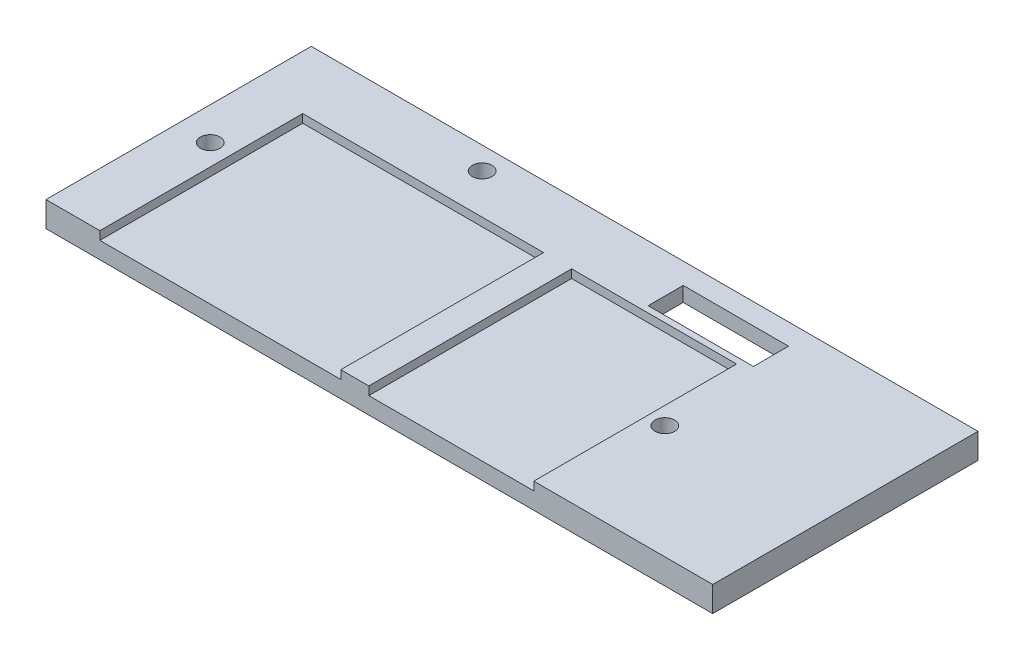
from build123d import *

# Parameters (mm, degrees)
SKETCH1_W           = 95
SKETCH1_H           = 37.8
BOSS_EXTRUDE1_DEPTH = 3.6
SKETCH2_R           = 1.4
CUT_EXTRUDE1_DEPTH  = 4
SKETCH3_W           = 6
SKETCH3_H           = 6
SKETCH3_W_2         = 7
SKETCH3_H_2         = 5
SKETCH3_W_3         = 5
CUT_EXTRUDE5_DEPTH  = 1.5
BOSS_EXTRUDE3_DEPTH = 1.5
SKETCH6_W           = 15
SKETCH6_H           = 5
CUT_EXTRUDE6_DEPTH  = 18.5
SKETCH7_W           = 10
SKETCH7_H           = 1.5
CUT_EXTRUDE7_DEPTH  = 2
SKETCH9_W           = 23
SKETCH9_H           = 1.5
CUT_EXTRUDE8_DEPTH  = 1.5
SKETCH10_W          = 18
SKETCH10_H          = 1.5
BOSS_EXTRUDE5_DEPTH = 1.5
SKETCH11_W          = 34.32
SKETCH11_H          = 28.9
SKETCH11_W_2        = 23.5
CUT_EXTRUDE10_DEPTH = 1.2
SKETCH12_W          = 1.5
SKETCH12_H          = 1.5
BOSS_EXTRUDE6_DEPTH = 0.5


with BuildPart() as part:
    # Sketch1 → Boss-Extrude1 (new body)
    with BuildSketch(Plane(origin=(0, 0, 0), x_dir=(1, 0, 0), z_dir=(0, 1, 0))):
        Rectangle(SKETCH1_W, SKETCH1_H)
    extrude(amount=BOSS_EXTRUDE1_DEPTH)

    # Sketch2 → Cut-Extrude1 (cut)
    with BuildSketch(Plane(origin=(0, 3.6, 0), x_dir=(1, 0, 0), z_dir=(0, 1, 0))):
        with Locations((-42.82, -0.18)):
            Circle(SKETCH2_R)
        with Locations((-19.96, 15.7)):
            Circle(SKETCH2_R)
        with Locations((24.5, -2.72)):
            Circle(SKETCH2_R)
    extrude(amount=-CUT_EXTRUDE1_DEPTH, mode=Mode.SUBTRACT)

    # Sketch3 → Cut-Extrude5 (cut)
    with BuildSketch(Plane.XZ):
        with Locations((-37.82, -9.62)):
            Rectangle(SKETCH3_W, SKETCH3_H)
        Polygon((28, -18.9), (7, -18.9), (7, -8.9), (11, -8.9), (28, -8.9), align=None)
        with BuildLine():
            Line((-19.26, -6.1), (-19.26, 15.9))
            Line((-19.26, 15.9), (22.74, 15.9))
            Line((22.74, 15.9), (22.74, 4.12))
            Line((22.74, 4.12), (24.5, 4.12))
            ThreePointArc((24.5, 4.12), (25.9, 2.72), (24.5, 1.32))
            Line((24.5, 1.32), (22.74, 1.32))
            Line((22.74, 1.32), (22.74, -6.1))
            Line((22.74, -6.1), (-19.26, -6.1))
        make_face()
        with Locations((42, -14.4)):
            Rectangle(SKETCH3_W_2, SKETCH3_H_2)
        with Locations((-14.76, -16.4)):
            Rectangle(SKETCH3_W_3, SKETCH3_H_2)
    extrude(amount=-CUT_EXTRUDE5_DEPTH, mode=Mode.SUBTRACT)

    # Sketch4 → Boss-Extrude3 (add)
    with BuildSketch(Plane.XZ.offset(-1.5)):
        with BuildLine():
            Line((22.74, 4.12), (22.74, 15.9))
            Line((22.74, 15.9), (20.74, 15.9))
            Line((20.74, 15.9), (20.74, 4.12))
            Line((20.74, 4.12), (20.74, -6.1))
            Line((20.74, -6.1), (22.74, -6.1))
            Line((22.74, -6.1), (22.74, 1.32))
            Line((22.74, 1.32), (24.5, 1.32))
            ThreePointArc((24.5, 1.32), (23.1, 2.72), (24.5, 4.12))
            Line((24.5, 4.12), (22.74, 4.12))
        make_face()
    extrude(amount=BOSS_EXTRUDE3_DEPTH)

    # Sketch6 → Cut-Extrude6 (cut)
    with BuildSketch(Plane(origin=(0, 3.6, 0), x_dir=(1, 0, 0), z_dir=(0, 1, 0))):
        with Locations((16, 13.4)):
            Rectangle(SKETCH6_W, SKETCH6_H)
    extrude(amount=-CUT_EXTRUDE6_DEPTH, mode=Mode.SUBTRACT)

    # Sketch7 → Cut-Extrude7 (cut)
    with BuildSketch(Plane.ZY.offset(-28)):
        with Locations((-13.9, 0.75)):
            Rectangle(SKETCH7_W, SKETCH7_H)
    extrude(amount=-CUT_EXTRUDE7_DEPTH, mode=Mode.SUBTRACT)

    # Sketch9 → Cut-Extrude8 (cut)
    with BuildSketch(Plane(origin=(0, 0, -8.9), x_dir=(-1, 0, 0), z_dir=(0, 0, -1))):
        with Locations((-18.5, 0.75)):
            Rectangle(SKETCH9_W, SKETCH9_H)
    extrude(amount=-CUT_EXTRUDE8_DEPTH, mode=Mode.SUBTRACT)

    # Sketch10 → Boss-Extrude5 (add)
    with BuildSketch(Plane.XZ.offset(-1.5)):
        with Locations((21, -18.15)):
            Rectangle(SKETCH10_W, SKETCH10_H)
    extrude(amount=BOSS_EXTRUDE5_DEPTH)

    # Sketch11 → Cut-Extrude10 (cut)
    with BuildSketch(Plane(origin=(0, 3.6, 0), x_dir=(1, 0, 0), z_dir=(0, 1, 0))):
        with Locations((-22.66, -4.45)):
            Rectangle(SKETCH11_W, SKETCH11_H)
        with Locations((10.25, -4.45)):
            Rectangle(SKETCH11_W_2, SKETCH11_H)
    extrude(amount=-CUT_EXTRUDE10_DEPTH, mode=Mode.SUBTRACT)

    # Sketch12 → Boss-Extrude6 (add)
    with BuildSketch(Plane.ZY.offset(-12)):
        with Locations((-18.15, 0.75)):
            Rectangle(SKETCH12_W, SKETCH12_H)
    extrude(amount=BOSS_EXTRUDE6_DEPTH)


solid = part.part
